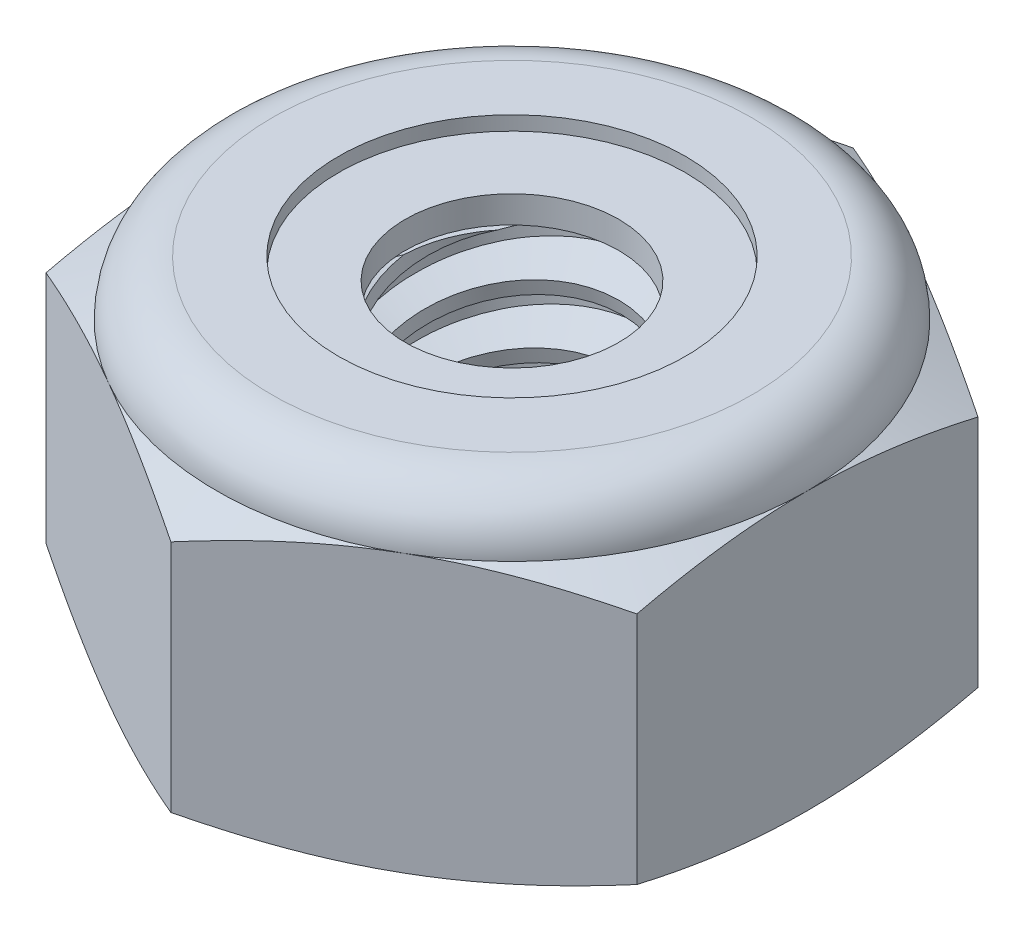
from build123d import *

# Parameters (mm, degrees)
EXTRUDE1_DEPTH      = 3.571875
SKETCH2_W           = 1.4224
SKETCH2_H           = 3.571875
LPATTERN1_COUNT     = 6
LPATTERN1_PITCH     = 0.635
LPATTERN1_COL_COUNT = 2
LPATTERN1_COL_PITCH = 0.635


with BuildPart() as part:
    # Sketch1 → Extrude1 (new body)
    with BuildSketch(Plane(origin=(0, 0, 0), x_dir=(1, 0, 0), z_dir=(0, 1, 0))):
        Polygon((0, 3.666174209), (-3.175, 1.833087105), (-3.175, -1.833087105), (0, -3.666174209), (3.175, -1.833087105), (3.175, 1.833087105), align=None)
    extrude(amount=EXTRUDE1_DEPTH)

    # Sketch4 → Cut-Revolve2 (revolve, cut)
    with BuildSketch(Plane(origin=(0, 0, 0), x_dir=(0, 0, -1), z_dir=(1, 0, 0))):
        Polygon((0, 3.571875), (1.4224, 3.571875), (1.147473684, 3.443674754), (1.147473684, 0.128200246), (1.4224, 0), (0, 0), align=None)
    revolve(axis=Axis((0, 3.571875, 0), (0, 1, 0)), mode=Mode.SUBTRACT)


with BuildPart() as body_2:
    # Sketch2 → Revolve1 (revolve)
    with BuildSketch(Plane(origin=(0, 0, 0), x_dir=(0, 0, -1), z_dir=(1, 0, 0))):
        with Locations((0.7112, 1.7859375)):
            Rectangle(SKETCH2_W, SKETCH2_H)
    revolve(axis=Axis((0, -1.4224, 0), (0, 1, 0)))

    # Sketch3 → Cut-Revolve1 (revolve, cut)
    with BuildSketch(Plane(origin=(0, 0, 0), x_dir=(0, 0, -1), z_dir=(1, 0, 0))):
        Polygon((1.439692084, 3.494406462), (1.560736676, 2.952126693), (1.182057853, 3.070921117), (1.147473684, 3.225858194), align=None)
    cut_revolve1 = revolve(axis=Axis((0, 3.571875, 0.152561988), (0, -0.975981586, -0.217853033)), mode=Mode.SUBTRACT)

    # LPattern1: Cut-Revolve1 ×6
    with Locations(*[(0, -i * LPATTERN1_PITCH, 0) for i in range(1, LPATTERN1_COUNT)]):
        add(cut_revolve1, mode=Mode.SUBTRACT)

    # LPattern1 col: Cut-Revolve1 ×2
    with Locations(*[(0, i * LPATTERN1_COL_PITCH, 0) for i in range(1, LPATTERN1_COL_COUNT)]):
        add(cut_revolve1, mode=Mode.SUBTRACT)


with BuildPart() as part_1:
    add(part.part)

    # Combine1: cut body 2
    add(body_2.part, mode=Mode.SUBTRACT)

    # Sketch5 → Cut-Revolve3 (revolve, cut)
    with BuildSketch(Plane(origin=(0, 0, 0), x_dir=(0, 0, -1), z_dir=(1, 0, 0))):
        with BuildLine():
            Line((0, 0), (3.175, 0))
            Line((3.175, 0), (3.666174209, 0.229038295))
            Line((3.666174209, 0.229038295), (3.666174209, 2.747524205))
            Line((3.666174209, 2.747524205), (3.175, 2.9765625))
            ThreePointArc((3.175, 2.9765625), (3.000637006, 3.397512006), (2.5796875, 3.571875))
            Line((2.5796875, 3.571875), (2.5796875, 4.841875))
            Line((2.5796875, 4.841875), (4.936174209, 4.841875))
            Line((4.936174209, 4.841875), (4.936174209, -1.27))
            Line((4.936174209, -1.27), (0, -1.27))
            Line((0, -1.27), (0, 0))
        make_face()
    revolve(axis=Axis((0, 0, 0), (0, 1, 0)), mode=Mode.SUBTRACT)

    # Sketch6 → Cut-Revolve4 (revolve, cut)
    with BuildSketch(Plane(origin=(0, 0, 0), x_dir=(0, 0, -1), z_dir=(1, 0, 0))):
        with BuildLine():
            Line((0, 2.9765625), (3.0226, 2.9765625))
            ThreePointArc((3.0226, 2.9765625), (2.892873932, 3.289748932), (2.5796875, 3.419475))
            Line((2.5796875, 3.419475), (1.863580592, 3.419475))
            Line((1.863580592, 3.419475), (1.863580592, 4.841875))
            Line((1.863580592, 4.841875), (0, 4.841875))
            Line((0, 4.841875), (0, 2.9765625))
        make_face()
    revolve(axis=Axis((0, 4.841875, 0), (0, 1, 0)), mode=Mode.SUBTRACT)


with BuildPart() as body_2_2:
    # Sketch7 → Revolve2 (revolve)
    with BuildSketch(Plane(origin=(0, 0, 0), x_dir=(0, 0, -1), z_dir=(1, 0, 0))):
        with BuildLine():
            Line((1.147473684, 3.0527625), (2.938395763, 3.0527625))
            ThreePointArc((2.938395763, 3.0527625), (2.810484559, 3.261537543), (2.5796875, 3.343275))
            Line((2.5796875, 3.343275), (1.147473684, 3.343275))
            Line((1.147473684, 3.343275), (1.147473684, 3.0527625))
        make_face()
    revolve(axis=Axis((0, 3.0527625, 0), (0, 1, 0)))


solid = Compound([part_1.part, body_2_2.part])
